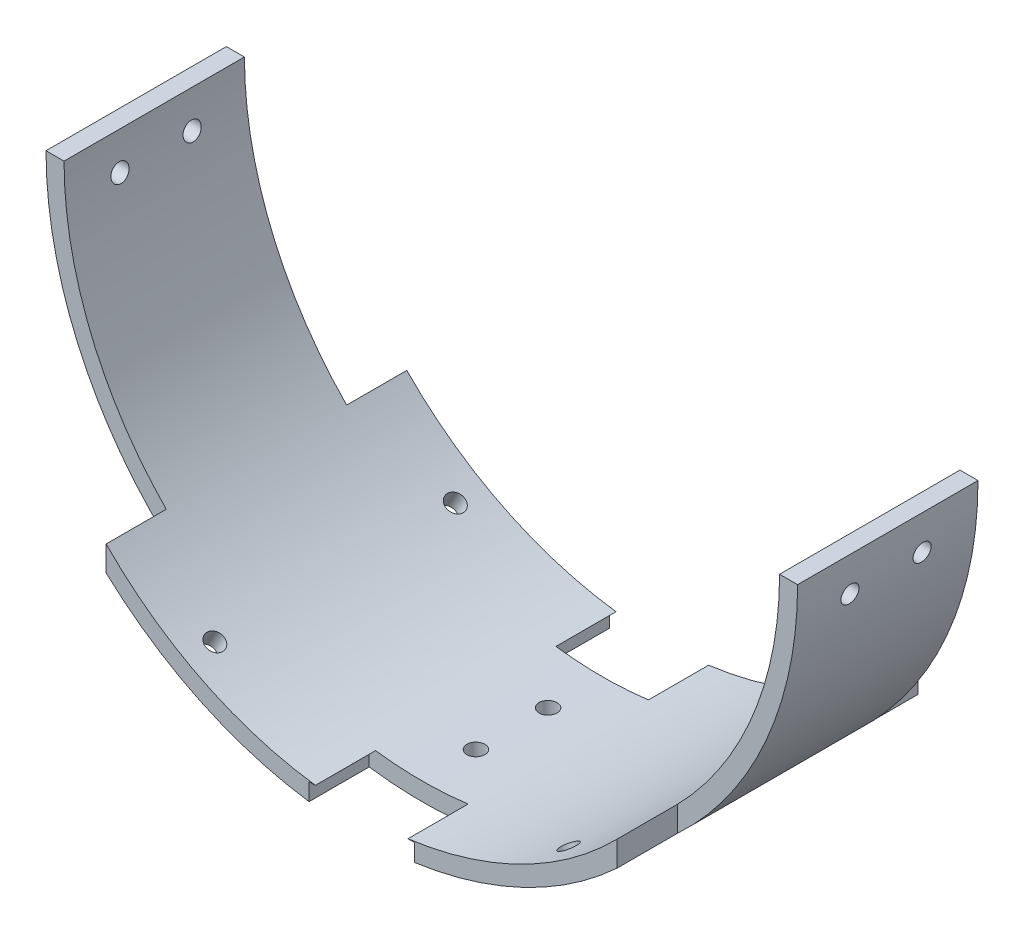
from build123d import *

# Parameters (mm, degrees)
BOSS_EXTRUDE1_DEPTH = 50
SKETCH3_W           = 20
SKETCH3_H           = 10
CUT_EXTRUDE2_DEPTH  = 102.550480058
SKETCH4_W           = 17.5
SKETCH4_H           = 7
CUT_EXTRUDE3_DEPTH  = 10
BOSS_EXTRUDE2_DEPTH = 10
CUT_EXTRUDE6_DEPTH  = 10
SKETCH16_R          = 1.5
CUT_EXTRUDE7_DEPTH  = 10
SKETCH17_R          = 1.5
CUT_EXTRUDE8_DEPTH  = 10
CUT_EXTRUDE9_START  = -10
SKETCH18_R          = 1.5
CUT_EXTRUDE9_DEPTH  = 137
SKETCH19_R          = 1.5
CUT_EXTRUDE10_DEPTH = 10


with BuildPart() as part:
    # Sketch1 → Boss-Extrude1 (new body)
    with BuildSketch(Plane.XY):
        with BuildLine():
            ThreePointArc((59.5, 0), (0, -59.5), (-59.5, 0))
            Line((-59.5, 0), (-62.5, 0))
            ThreePointArc((-62.5, 0), (0, -62.5), (62.5, 0))
            Line((62.5, 0), (59.5, 0))
        make_face()
    extrude(amount=BOSS_EXTRUDE1_DEPTH)

    # Sketch3 → Cut-Extrude2 (cut, symmetric)
    with BuildSketch(Plane(origin=(0, 0, 0), x_dir=(1, 0, 0), z_dir=(0, 1, 0))):
        with Locations((-52.5, -45)):
            Rectangle(SKETCH3_W, SKETCH3_H)
        with Locations((52.5, -45)):
            Rectangle(SKETCH3_W, SKETCH3_H)
    cut_extrude2 = extrude(amount=CUT_EXTRUDE2_DEPTH, both=True, mode=Mode.SUBTRACT)

    # Sketch4 → Cut-Extrude3 (cut)
    with BuildSketch(Plane.XY.offset(50)):
        with Locations((0, -62.5)):
            Rectangle(SKETCH4_W, SKETCH4_H)
    cut_extrude3 = extrude(amount=-CUT_EXTRUDE3_DEPTH, mode=Mode.SUBTRACT)

    # Sketch9 → Boss-Extrude2 (add)
    with BuildSketch(Plane.XY):
        with BuildLine():
            Line((-52.112697755, -24.30055005), (-55.284775009, -25.779713966))
            ThreePointArc((-55.284775009, -25.779713966), (-51.730933866, -32.325075118), (-47.405903649, -38.388543854))
            Line((-47.405903649, -38.388543854), (-44.685892784, -36.185922485))
            ThreePointArc((-44.685892784, -36.185922485), (-48.762765529, -30.470357693), (-52.112697755, -24.30055005))
        make_face()
        with BuildLine():
            ThreePointArc((47.405903649, -38.388543854), (51.730933866, -32.325075118), (55.284775009, -25.779713966))
            Line((55.284775009, -25.779713966), (52.112697755, -24.30055005))
            ThreePointArc((52.112697755, -24.30055005), (48.762765529, -30.470357693), (44.685892784, -36.185922485))
            Line((44.685892784, -36.185922485), (47.405903649, -38.388543854))
        make_face()
        with BuildLine():
            Line((-7.007487246, -57.071403719), (-7.434029948, -60.54531525))
            ThreePointArc((-7.434029948, -60.54531525), (0, -61), (7.434029948, -60.54531525))
            Line((7.434029948, -60.54531525), (7.007487246, -57.071403719))
            ThreePointArc((7.007487246, -57.071403719), (0, -57.5), (-7.007487246, -57.071403719))
        make_face()
    boss_extrude2 = extrude(amount=BOSS_EXTRUDE2_DEPTH)

    # Sketch15 → Cut-Extrude6 (cut)
    with BuildSketch(Plane.XY):
        with BuildLine():
            Line((-52.112697755, -24.30055005), (-55.284775009, -25.779713966))
            ThreePointArc((-55.284775009, -25.779713966), (-51.730933866, -32.325075118), (-47.405903649, -38.388543854))
            Line((-47.405903649, -38.388543854), (-44.685892784, -36.185922485))
            ThreePointArc((-44.685892784, -36.185922485), (-48.762765529, -30.470357693), (-52.112697755, -24.30055005))
        make_face()
        with BuildLine():
            ThreePointArc((47.405903649, -38.388543854), (51.730933866, -32.325075118), (55.284775009, -25.779713966))
            Line((55.284775009, -25.779713966), (52.112697755, -24.30055005))
            ThreePointArc((52.112697755, -24.30055005), (48.762765529, -30.470357693), (44.685892784, -36.185922485))
            Line((44.685892784, -36.185922485), (47.405903649, -38.388543854))
        make_face()
        with BuildLine():
            Line((-7.007487246, -57.071403719), (-7.434029948, -60.54531525))
            ThreePointArc((-7.434029948, -60.54531525), (0, -61), (7.434029948, -60.54531525))
            Line((7.434029948, -60.54531525), (7.007487246, -57.071403719))
            ThreePointArc((7.007487246, -57.071403719), (0, -57.5), (-7.007487246, -57.071403719))
        make_face()
    cut_extrude6 = extrude(amount=CUT_EXTRUDE6_DEPTH, mode=Mode.SUBTRACT)

    # Sketch16 → Cut-Extrude7 (cut, symmetric)
    with BuildSketch(Plane(origin=(-28.846172405, -52.039872575, 0), x_dir=(0.8746197071393955, -0.48480962024633767, 0), z_dir=(0.4848096202463376, 0.8746197071393954, 0))):
        with Locations((-0.663731696, -45)):
            Circle(SKETCH16_R)
    cut_extrude7 = extrude(amount=CUT_EXTRUDE7_DEPTH, both=True, mode=Mode.SUBTRACT)

    # Sketch17 → Cut-Extrude8 (cut, symmetric)
    with BuildSketch(Plane(origin=(28.846172405, -52.039872575, 0), x_dir=(0.8746197071393965, 0.4848096202463359, 0), z_dir=(-0.48480962024633584, 0.8746197071393964, 0))):
        with Locations((0.663731696, -45)):
            Circle(SKETCH17_R)
    cut_extrude8 = extrude(amount=CUT_EXTRUDE8_DEPTH, both=True, mode=Mode.SUBTRACT)

    # Sketch18 → Cut-Extrude9 (cut)
    with BuildSketch(Plane(origin=(59.5, 0, 0), x_dir=(0, 1, 0), z_dir=(-1, 0, 0)).offset(CUT_EXTRUDE9_START)):
        with Locations((-6, -31)):
            Circle(SKETCH18_R)
    cut_extrude9 = extrude(amount=CUT_EXTRUDE9_DEPTH, mode=Mode.SUBTRACT)

    # Sketch19 → Cut-Extrude10 (cut, symmetric)
    with BuildSketch(Plane(origin=(0, -59.5, 0), x_dir=(1, 0, 0), z_dir=(0, 1, 0))):
        with Locations((0, -31)):
            Circle(SKETCH19_R)
    cut_extrude10 = extrude(amount=CUT_EXTRUDE10_DEPTH, both=True, mode=Mode.SUBTRACT)

    # Mirror4: Cut-Extrude2, Cut-Extrude3, Boss-Extrude2, Cut-Extrude6, Cut-Extrude7, Cut-Extrude8, Cut-Extrude9, Cut-Extrude10 across plane
    add(cut_extrude2.mirror(Plane.XY.offset(25)), mode=Mode.SUBTRACT)
    add(cut_extrude3.mirror(Plane.XY.offset(25)), mode=Mode.SUBTRACT)
    add(boss_extrude2.mirror(Plane.XY.offset(25)))
    add(cut_extrude6.mirror(Plane.XY.offset(25)), mode=Mode.SUBTRACT)
    add(cut_extrude7.mirror(Plane.XY.offset(25)), mode=Mode.SUBTRACT)
    add(cut_extrude8.mirror(Plane.XY.offset(25)), mode=Mode.SUBTRACT)
    add(cut_extrude9.mirror(Plane.XY.offset(25)), mode=Mode.SUBTRACT)
    add(cut_extrude10.mirror(Plane.XY.offset(25)), mode=Mode.SUBTRACT)


solid = part.part
